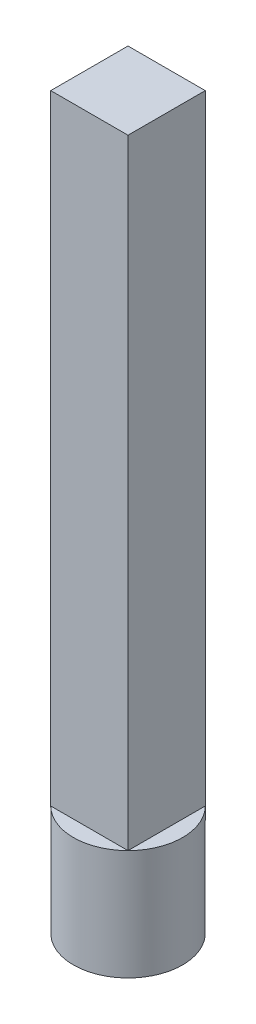
from build123d import *

# Parameters (mm, degrees)
SKETCH1_W           = 20
SKETCH1_H           = 20
BOSS_EXTRUDE2_DEPTH = 160.4
SKETCH1_3_W         = 20
SKETCH1_3_H         = 20
BOSS_EXTRUDE3_DEPTH = 28.575


with BuildPart() as part:
    # Sketch1 → Boss-Extrude2 (new body)
    with BuildSketch(Plane(origin=(0, 0, 0), x_dir=(1, 0, 0), z_dir=(0, 1, 0))):
        Rectangle(SKETCH1_W, SKETCH1_H)
    extrude(amount=BOSS_EXTRUDE2_DEPTH)

    # Sketch1_3 → Boss-Extrude3 (add)
    with BuildSketch(Plane(origin=(0, 0, 0), x_dir=(1, 0, 0), z_dir=(0, 1, 0))):
        with BuildLine():
            Line((10, -10), (-10, -10))
            ThreePointArc((-10, -10), (0, -14.142135624), (10, -10))
        make_face()
        with BuildLine():
            ThreePointArc((-10, 10), (-14.142135624, 0), (-10, -10))
            Line((-10, -10), (-10, 10))
        make_face()
        Rectangle(SKETCH1_3_W, SKETCH1_3_H)
        with BuildLine():
            Line((10, 10), (10, -10))
            ThreePointArc((10, -10), (13.065629649, -5.411961001), (14.142135624, 0))
            ThreePointArc((14.142135624, 0), (13.065629649, 5.411961001), (10, 10))
        make_face()
        with BuildLine():
            ThreePointArc((10, 10), (0, 14.142135624), (-10, 10))
            Line((-10, 10), (10, 10))
        make_face()
    extrude(amount=-BOSS_EXTRUDE3_DEPTH)


solid = part.part
